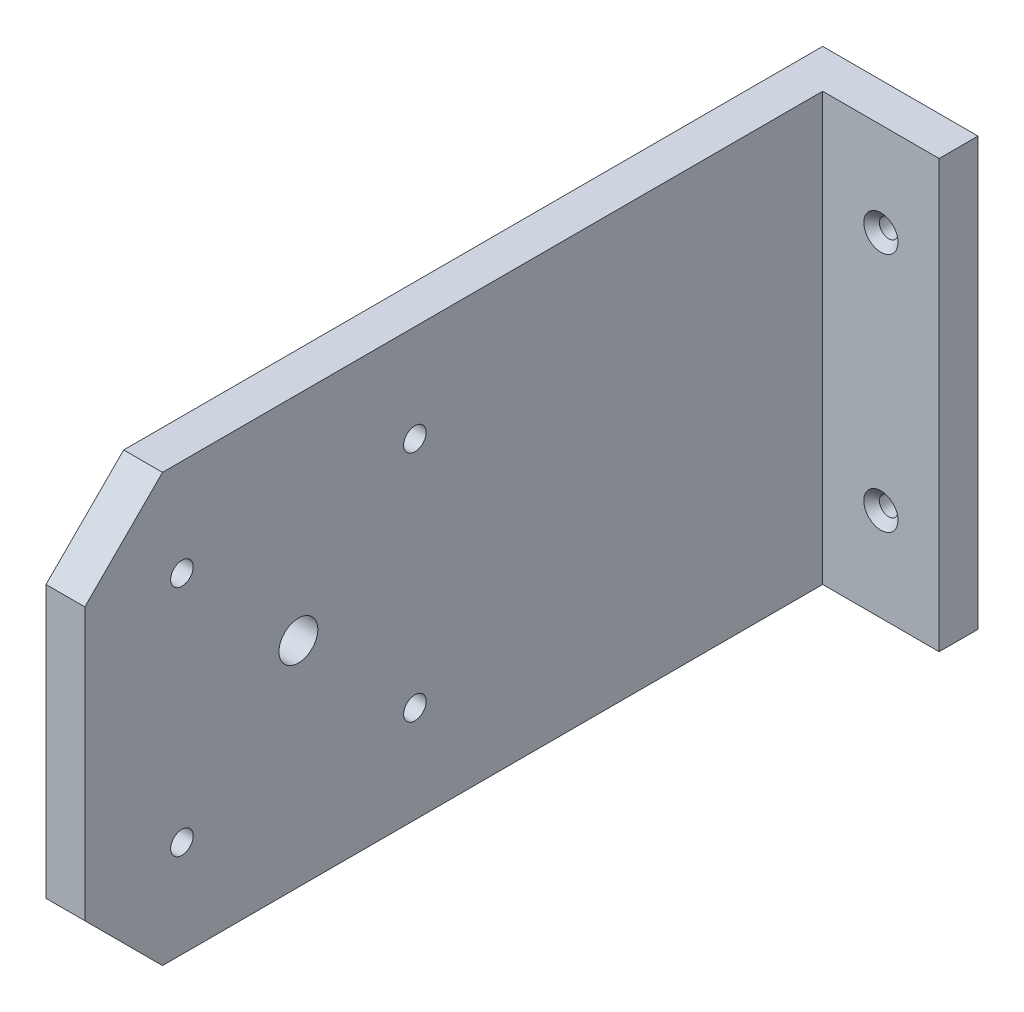
from build123d import *

# Parameters (mm, degrees)
SKETCH1_W                                         = 100
SKETCH1_H                                         = 55
BOSS_EXTRUDE1_DEPTH                               = 5
SKETCH2_W                                         = 5
SKETCH2_H                                         = 55
BOSS_EXTRUDE2_DEPTH                               = 15
CUT_EXTRUDE1_REACH                                = 22
CSK_FOR_M2_FLAT_HEAD_MACHINE_SCREW1_D             = 2.4
CSK_FOR_M2_FLAT_HEAD_MACHINE_SCREW1_CSINK_D       = 4.4
CSK_FOR_M2_FLAT_HEAD_MACHINE_SCREW1_CSINK_ANGLE   = 90
CUT_EXTRUDE2_REACH                                = 22
SKETCH6_R                                         = 2.5
CSK_FOR_M2_5_FLAT_HEAD_MACHINE_SCREW1_D           = 2.9
CSK_FOR_M2_5_FLAT_HEAD_MACHINE_SCREW1_DEPTH       = 5
CSK_FOR_M2_5_FLAT_HEAD_MACHINE_SCREW1_CSINK_D     = 5.5
CSK_FOR_M2_5_FLAT_HEAD_MACHINE_SCREW1_CSINK_ANGLE = 90


with BuildPart() as part:
    # Sketch1 → Boss-Extrude1 (new body)
    with BuildSketch(Plane(origin=(0, 0, 0), x_dir=(0, 0, -1), z_dir=(1, 0, 0))):
        Rectangle(SKETCH1_W, SKETCH1_H)
    extrude(amount=BOSS_EXTRUDE1_DEPTH)

    # Sketch2 → Boss-Extrude2 (add)
    with BuildSketch(Plane(origin=(5, 0, 0), x_dir=(0, 0, -1), z_dir=(1, 0, 0))):
        with Locations((47.5, 0)):
            Rectangle(SKETCH2_W, SKETCH2_H)
    extrude(amount=BOSS_EXTRUDE2_DEPTH)

    # Sketch3 → Cut-Extrude1 (cut, up to next)
    with BuildSketch(Plane.ZY, mode=Mode.PRIVATE) as cut_extrude1_sk1:
        Polygon((50, 27.5), (40, 27.5), (50, 17.5), align=None)
    cut_extrude1_tool1 = extrude(cut_extrude1_sk1.sketch, amount=-CUT_EXTRUDE1_REACH, mode=Mode.PRIVATE) & part.part
    add(cut_extrude1_tool1.solids().sort_by_distance((0, 24.166667, 46.666667))[0], mode=Mode.SUBTRACT)
    # Sketch3 → Cut-Extrude1 (cut, up to next)
    with BuildSketch(Plane.ZY, mode=Mode.PRIVATE) as cut_extrude1_sk2:
        Polygon((50, -27.5), (40, -27.5), (50, -17.5), align=None)
    cut_extrude1_tool2 = extrude(cut_extrude1_sk2.sketch, amount=-CUT_EXTRUDE1_REACH, mode=Mode.PRIVATE) & part.part
    add(cut_extrude1_tool2.solids().sort_by_distance((0, -24.166667, 46.666667))[0], mode=Mode.SUBTRACT)

    # CSK for M2 Flat Head Machine Screw1 (through all)
    with Locations(Plane.XY.offset(-45)):
        with Locations((12.5, 15.5), (12.5, -15.5)):
            CounterSinkHole(CSK_FOR_M2_FLAT_HEAD_MACHINE_SCREW1_D / 2, CSK_FOR_M2_FLAT_HEAD_MACHINE_SCREW1_CSINK_D / 2, counter_sink_angle=CSK_FOR_M2_FLAT_HEAD_MACHINE_SCREW1_CSINK_ANGLE)

    # Sketch6 → Cut-Extrude2 (cut, up to next)
    with BuildSketch(Plane.ZY, mode=Mode.PRIVATE) as cut_extrude2_sk1:
        with Locations((22.5, 0)):
            Circle(SKETCH6_R)
    cut_extrude2_tool1 = extrude(cut_extrude2_sk1.sketch, amount=-CUT_EXTRUDE2_REACH, mode=Mode.PRIVATE) & part.part
    add(cut_extrude2_tool1.solids().sort_by_distance((0, 0, 22.5))[0], mode=Mode.SUBTRACT)

    # CSK for M2.5 Flat Head Machine Screw1
    with Locations(Plane.ZY):
        with Locations((7.5, 15), (7.5, -15), (37.5, -15), (37.5, 15)):
            CounterSinkHole(CSK_FOR_M2_5_FLAT_HEAD_MACHINE_SCREW1_D / 2, CSK_FOR_M2_5_FLAT_HEAD_MACHINE_SCREW1_CSINK_D / 2, depth=CSK_FOR_M2_5_FLAT_HEAD_MACHINE_SCREW1_DEPTH, counter_sink_angle=CSK_FOR_M2_5_FLAT_HEAD_MACHINE_SCREW1_CSINK_ANGLE)


solid = part.part
